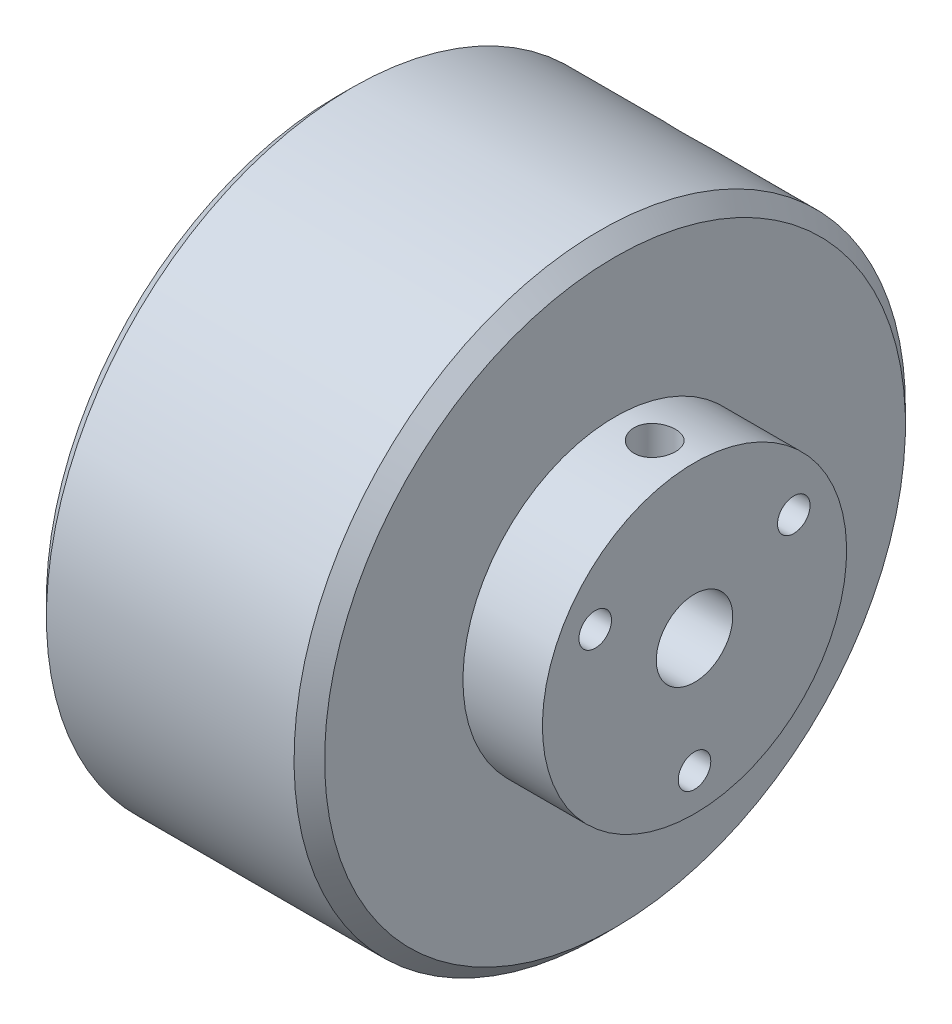
from build123d import *

# Parameters (mm, degrees)
SKETCH2_R                = 3.175
BORE_DEPTH               = 37.322
FACE_MOUNT_SCREWS_D      = 2.7051
SKETCH5_W                = 1.7272
SKETCH5_H                = 25.4
SET_SCREWS_AT_2_COUNT    = 2
SET_SCREWS_AT_2_PITCH    = 29.718
CHAMFER1_SIZE            = 1.27
SKETCH15_R               = 1.5
BOSS_EXTRUDE1_DEPTH      = 1
BOSS_EXTRUDE1_DEPTH_BACK = 20.32
SKETCH16_R               = 2.75
BOSS_EXTRUDE2_DEPTH      = 3
CHAMFER2_SIZE            = 0.381
CUT_EXTRUDE2_DEPTH       = 2
LPATTERN2_COUNT          = 2
LPATTERN2_PITCH          = 6
LPATTERN2_2_COUNT        = 2
LPATTERN2_2_PITCH        = 6
SKETCH18_R               = 12.6365
SKETCH18_R_2             = 3.175
CUT_EXTRUDE3_DEPTH       = 0.0635


with BuildPart() as part:
    # Sketch1 → Hub (revolve)
    with BuildSketch(Plane.XY, mode=Mode.PRIVATE) as hub_sk:
        Polygon((-11.557, 25.4), (11.557, 25.4), (11.557, 12.6365), (18.161, 12.6365), (18.161, 0), (-18.161, 0), (-18.161, 12.6365), (-11.557, 12.6365), align=None)
    revolve(hub_sk.sketch.rotate(Axis((-18.161, 0, 0), (1, 0, 0)), 180), axis=Axis((-18.161, 0, 0), (1, 0, 0)))  # turned: the seam where the file's is

    # Sketch2 → Bore (cut, through all)
    with BuildSketch(Plane(origin=(18.161, 0, 0), x_dir=(0, 0, -1), z_dir=(1, 0, 0))):
        with Locations(Location((0, 0, 0), (0, 0, 90))):  # turned: the seam where the file's is
            Circle(SKETCH2_R)
    extrude(amount=-BORE_DEPTH, mode=Mode.SUBTRACT)

    # Face Mount Screws (through all)
    with Locations(Plane(origin=(18.161, 0, 0), x_dir=(0, 0, -1), z_dir=(1, 0, 0))):
        with Locations((-8.248891971, 4.7625), (8.248891971, 4.7625), (0, -9.525)):
            Hole(FACE_MOUNT_SCREWS_D / 2)

    # Sketch5 → Set Screws (revolve, cut)
    with BuildSketch(Plane(origin=(-14.859, 0, 0), x_dir=(0, 0, -1), z_dir=(1, 0, 0))):
        with Locations((0.8636, 12.7)):
            Rectangle(SKETCH5_W, SKETCH5_H)
    set_screws = revolve(axis=Axis((-14.859, -6.35, 0), (0, 1, 0)), mode=Mode.SUBTRACT)

    # Set Screws at 2: Set Screws ×2
    with Locations(*[(i * SET_SCREWS_AT_2_PITCH, 0, 0) for i in range(1, SET_SCREWS_AT_2_COUNT)]):
        add(set_screws, mode=Mode.SUBTRACT)

    # Chamfer1
    chamfer1_edges = [part.edges().sort_by_distance(p)[0] for p in [
        (-11.557, 25.4, 0),
        (11.557, 25.4, 0),
    ]]
    chamfer(chamfer1_edges, length=CHAMFER1_SIZE)

    # Sketch12 → Cut-Revolve1 (revolve, cut)
    with BuildSketch(Plane.XY.offset(-20.32), mode=Mode.PRIVATE) as cut_revolve1_sk:
        Polygon((-3.25, 25.4), (-3.25, 7.62), (-1.7, 7.62), (-1.7, -25.4), (0, -25.4), (0, 25.4), align=None)
    revolve(cut_revolve1_sk.sketch.rotate(Axis((0, -25.4, -20.32), (0, 1, 0)), 180), axis=Axis((0, -25.4, -20.32), (0, 1, 0)), mode=Mode.SUBTRACT)  # turned: the seam where the file's is

    # Sketch14 → Cut-Revolve2 (revolve, cut)
    with BuildSketch(Plane.XY.offset(-20.32)):
        Polygon((-5.9935, -25.4), (-9.2435, -25.4), (-9.2435, -7.62), (-7.6935, -7.62), (-7.6935, 25.4), (-5.9935, 25.4), align=None)
    cut_revolve2 = revolve(axis=Axis((-5.9935, 25.4, -20.32), (0, -1, 0)), mode=Mode.SUBTRACT)

    # Mirror2: Cut-Revolve2 across plane
    add(cut_revolve2.mirror(Plane(origin=(0, 0, 0), x_dir=(0, 0, 1), z_dir=(1, 0, 0))), mode=Mode.SUBTRACT)

    # Sketch18 → Cut-Extrude3 (cut, symmetric)
    with BuildSketch(Plane(origin=(0, 0, 0), x_dir=(0, 0, -1), z_dir=(1, 0, 0))):
        with Locations(Location((0, 0, 0), (0, 0, 270))):  # turned: the seam where the file's is
            Circle(SKETCH18_R)
        with Locations(Location((0, 0, 0), (0, 0, 90))):  # turned: the seam where the file's is
            Circle(SKETCH18_R_2, mode=Mode.SUBTRACT)
    extrude(amount=CUT_EXTRUDE3_DEPTH, both=True, mode=Mode.SUBTRACT)


with BuildPart() as body_2:
    # Sketch15 → Boss-Extrude1 (new body, two sides)
    with BuildSketch(Plane(origin=(0, 7.62, 0), x_dir=(1, 0, 0), z_dir=(0, 1, 0))) as boss_extrude1_sk:
        with Locations(Location((0, 20.32, 0), (0, 0, 180))):  # turned: the seam where the file's is
            Circle(SKETCH15_R)
    extrude(amount=BOSS_EXTRUDE1_DEPTH)
    extrude(boss_extrude1_sk.sketch, amount=-BOSS_EXTRUDE1_DEPTH_BACK)

    # Sketch16 → Boss-Extrude2 (add)
    with BuildSketch(Plane(origin=(0, 8.62, 0), x_dir=(1, 0, 0), z_dir=(0, 1, 0))):
        with Locations(Location((0, 20.32, 0), (0, 0, 180))):  # turned: the seam where the file's is
            Circle(SKETCH16_R)
    extrude(amount=BOSS_EXTRUDE2_DEPTH)

    # Chamfer2
    chamfer2_edges = [body_2.edges().sort_by_distance(p)[0] for p in [
        (1.5, -12.7, -20.32),
        (2.75, 11.62, -20.32),
    ]]
    chamfer(chamfer2_edges, length=CHAMFER2_SIZE)

    # Sketch17 → Cut-Extrude2 (cut)
    with BuildSketch(Plane(origin=(0, 11.62, 0), x_dir=(1, 0, 0), z_dir=(0, 1, 0))):
        Polygon((0.721687836, 21.57), (-0.721687836, 21.57), (-1.443375673, 20.32), (-0.721687836, 19.07), (0.721687836, 19.07), (1.443375673, 20.32), align=None)
    extrude(amount=-CUT_EXTRUDE2_DEPTH, mode=Mode.SUBTRACT)


with BuildPart() as lpattern2_1:
    # LPattern2: pattern copy
    add(body_2.part.moved(Location(Vector(1, 0, 0) * (1 * LPATTERN2_PITCH))))


with BuildPart() as lpattern2_2_1:
    # LPattern2 2: pattern copy
    add(body_2.part.moved(Location(Vector(-1, 0, 0) * (1 * LPATTERN2_2_PITCH))))


with BuildPart() as body_5:
    # Mirror4: mirrored copy
    add(lpattern2_1.part.mirror(Plane.ZX))


with BuildPart() as body_6:
    # Mirror4 2: mirrored copy
    add(lpattern2_2_1.part.mirror(Plane.ZX))


solid = Compound([part.part, body_2.part, body_5.part, body_6.part])
